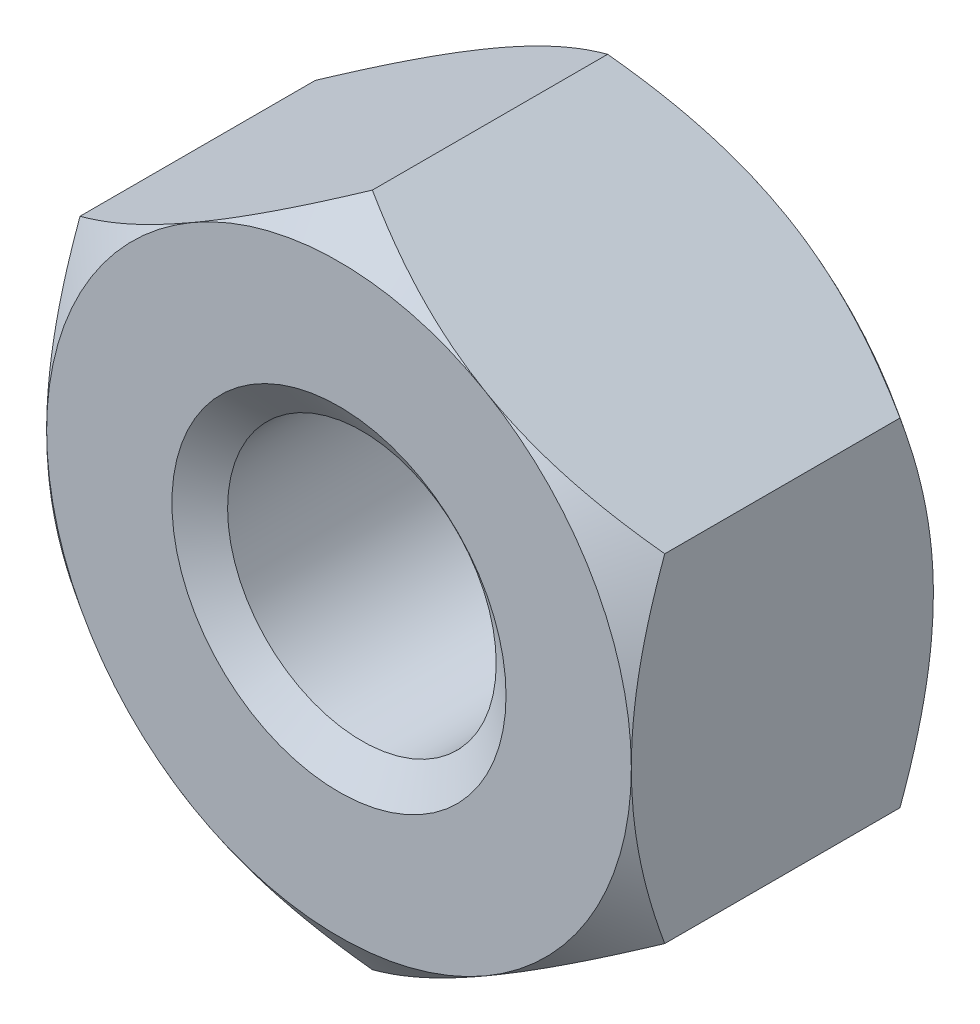
from build123d import *

# Parameters (mm, degrees)
BASENUTSKE_R  = 2.5527
BASENUT_DEPTH = 5.7404


with BuildPart() as part:
    # BaseNutSke → BaseNut (new body)
    with BuildSketch(Plane.XY):
        Polygon((5.55625, 3.207902433), (5.55625, -3.207902433), (0, -6.415804866), (-5.55625, -3.207902433), (-5.55625, 3.207902433), (0, 6.415804866), align=None)
        Circle(BASENUTSKE_R, mode=Mode.SUBTRACT)
    extrude(amount=-BASENUT_DEPTH)

    # Sketch3 → Double-Chamfer (revolve, cut)
    with BuildSketch(Plane(origin=(0, 0, 0), x_dir=(0, 0, -1), z_dir=(1, 0, 0))):
        Polygon((5.7404, 5.55625), (5.1054, 6.415804866), (5.1054, 19.115804866), (18.4404, 19.115804866), (18.4404, 5.55625), align=None)
        Polygon((0.635, 19.115804866), (-12.7, 19.115804866), (-12.7, 5.55625), (0, 5.55625), (0.635, 6.415804866), align=None)
    revolve(axis=Axis((0, 0, 0), (0, 0, -1)), mode=Mode.SUBTRACT)

    # Sketch5 → EndChamfer (revolve, cut)
    with BuildSketch(Plane(origin=(0, 0, 0), x_dir=(0, 0, -1), z_dir=(1, 0, 0))):
        Polygon((5.715, 3.175), (5.235686934, 2.49047), (5.7658, 2.49047), (5.7658, 3.175), align=None)
        Polygon((-0.0508, 3.175), (0, 3.175), (0.479313066, 2.49047), (-0.0508, 2.49047), align=None)
    revolve(axis=Axis((0, 0, -25.037505729), (0, 0, -1)), mode=Mode.SUBTRACT)


solid = part.part
